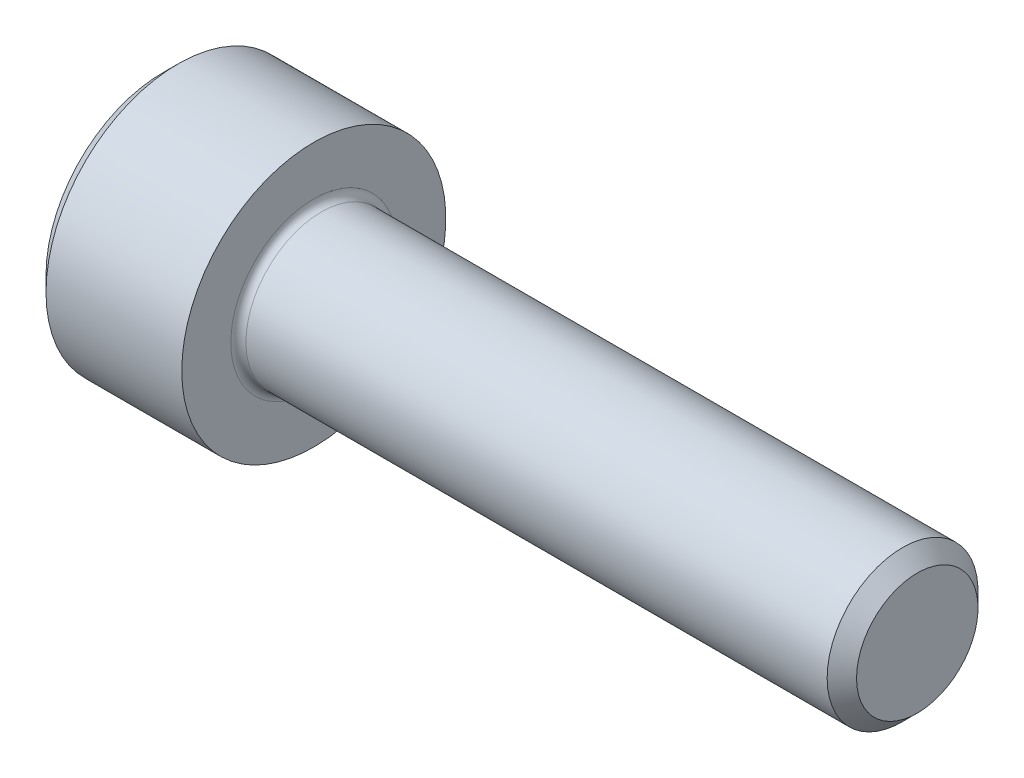
from build123d import *

# Parameters (mm, degrees)
FILLET1_R   = 0.2
HEX_2_DEPTH = 2


with BuildPart() as part:
    # BodySke → Base-Revolve (revolve)
    with BuildSketch(Plane.XY):
        Polygon((0, 0), (0, 3.1), (0.4, 3.5), (4, 3.5), (4, 2), (19.61, 2), (20, 1.61), (20, 0), align=None)
    revolve(axis=Axis((-31.75, 0, 0), (1, 0, 0)))

    # Fillet1
    fillet1_edges = [part.edges().sort_by_distance(p)[0] for p in [
        (4, -2, 0),
    ]]
    fillet(fillet1_edges, radius=FILLET1_R)

    # Sketch2 → Hex-PreBroach (revolve, cut)
    with BuildSketch(Plane.XY):
        Polygon((0, 1.5355), (2, 1.5355), (2.886521338, 0), (0, 0), align=None)
    revolve(axis=Axis((0, 0, 0), (1, 0, 0)), mode=Mode.SUBTRACT)

    # Sketch3 → Hex 2 (cut)
    with BuildSketch(Plane(origin=(0, 0, 0), x_dir=(0, 0.5, 0.866025404), z_dir=(-1, 0, 0))):
        Polygon((0.886521338, 1.5355), (-0.886521338, 1.5355), (-1.773042677, 0), (-0.886521338, -1.5355), (0.886521338, -1.5355), (1.773042677, 0), align=None)
    extrude(amount=-HEX_2_DEPTH, mode=Mode.SUBTRACT)


solid = part.part
